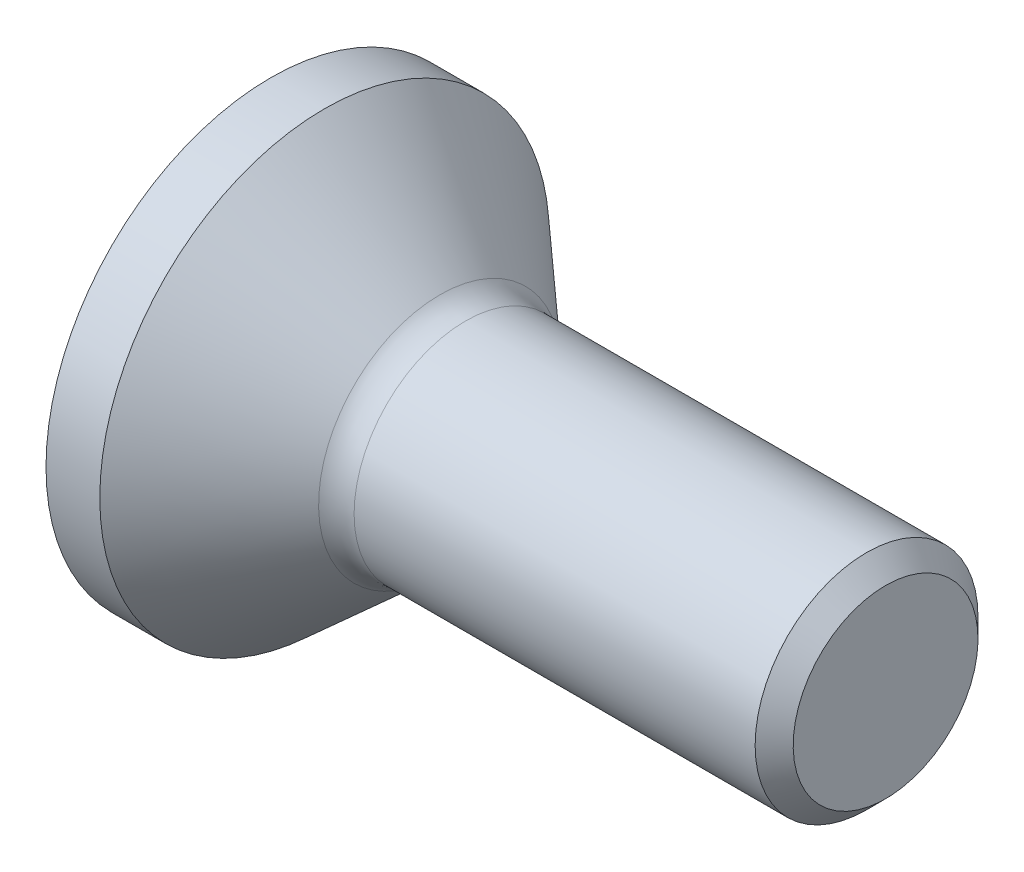
from build123d import *

# Parameters (mm, degrees)
CUT_EXTRUDE1_DEPTH = 1.5


with BuildPart() as part:
    # Sketch1 → Revolve1 (revolve)
    with BuildSketch(Plane.XY):
        with BuildLine():
            Line((2.534073147, 1.45), (7.752512627, 1.45))
            Line((7.752512627, 1.45), (8, 1.202512627))
            Line((8, 1.202512627), (8, 0))
            Line((8, 0), (0, 0))
            Line((0, 0), (0, 2.925))
            Line((0, 2.925), (0.7, 2.925))
            Line((0.7, 2.925), (2.2, 1.577985037))
            ThreePointArc((2.2, 1.577985037), (2.355198165, 1.483091293), (2.534073147, 1.45))
        make_face()
    revolve(axis=Axis((0, 0, 0), (-1, 0, 0)))

    # Sketch2 → Cut-Extrude1 (cut)
    with BuildSketch(Plane.ZY):
        Polygon((1, 0.577350269), (0, 1.154700538), (-1, 0.577350269), (-1, -0.577350269), (0, -1.154700538), (1, -0.577350269), align=None)
    extrude(amount=-CUT_EXTRUDE1_DEPTH, mode=Mode.SUBTRACT)


solid = part.part
